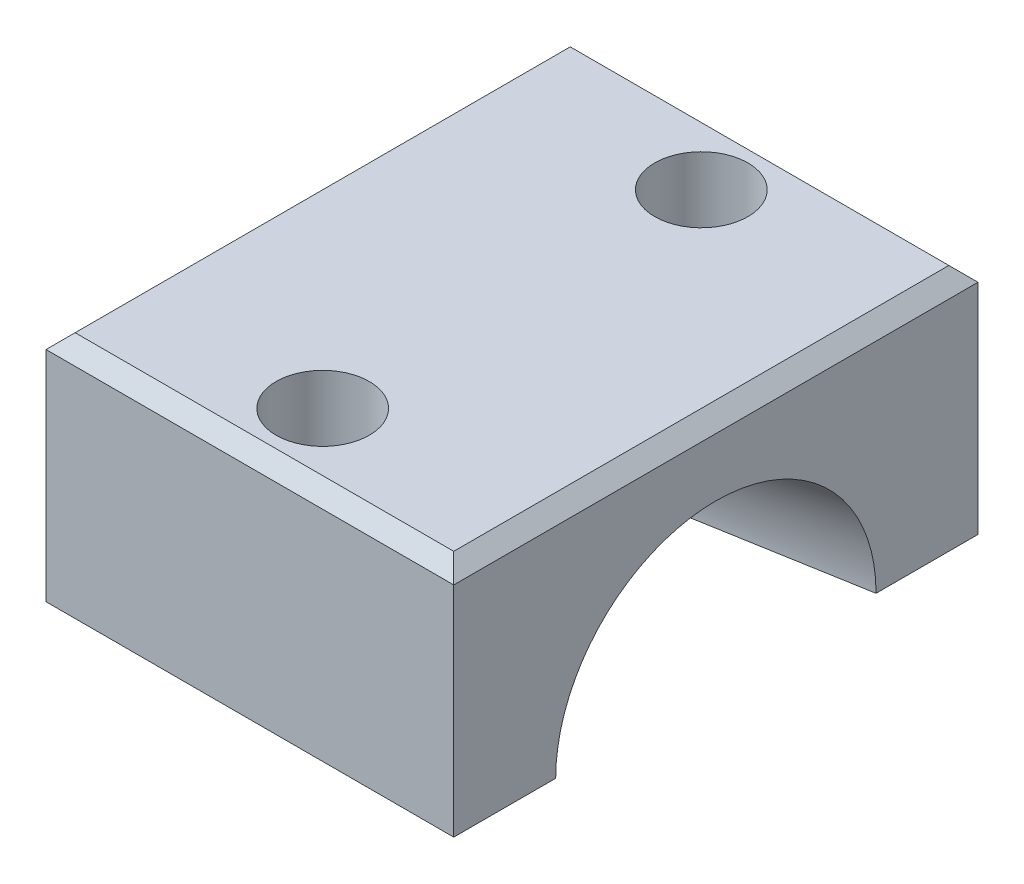
from build123d import *

# Parameters (mm, degrees)
SKETCH_1_W          = 14
SKETCH_1_H          = 18
SKETCH_1_R          = 1.6
EXTRUDE_1_DEPTH     = 4
SKETCH_2_R          = 3.5
CUT_EXTRUDE_1_DEPTH = 2.5
SKETCH_4_R          = 5.5
SKETCH_3_R          = 3.5
CHAMFER_1_SIZE      = 0.5


with BuildPart() as part:
    # 草圖1 → 填料-伸長1 (new body, symmetric)
    with BuildSketch(Plane(origin=(0, 0, 0), x_dir=(1, 0, 0), z_dir=(0, 1, 0))):
        Rectangle(SKETCH_1_W, SKETCH_1_H)
        with Locations((0, 6.5)):
            Circle(SKETCH_1_R, mode=Mode.SUBTRACT)
        with Locations((0, -6.5)):
            Circle(SKETCH_1_R, mode=Mode.SUBTRACT)
    extrude(amount=EXTRUDE_1_DEPTH, both=True)

    # 草圖2 → 除料-伸長1 (cut)
    with BuildSketch(Plane.ZY.offset(7)):
        with Locations((0, -4)):
            Circle(SKETCH_2_R)
    extrude(amount=-CUT_EXTRUDE_1_DEPTH, mode=Mode.SUBTRACT)

    # 草圖4 → 除料-疊層拉伸1 section 0
    with BuildSketch(Plane(origin=(7, 0, 0), x_dir=(0, 0, -1), z_dir=(1, 0, 0))):
        with Locations((0, -4)):
            Circle(SKETCH_4_R)
    # 草圖3 → 除料-疊層拉伸1 section 1
    with BuildSketch(Plane.ZY.offset(4.5)):
        with Locations((0, -4)):
            Circle(SKETCH_3_R)
    loft(mode=Mode.SUBTRACT)

    # 導角1
    chamfer_1_edges = [part.edges().sort_by_distance(p)[0] for p in [
        (-7, 4, 0),
        (0, 4, 9),
        (7, 4, 0),
        (0, 4, -9),
    ]]
    chamfer(chamfer_1_edges, length=CHAMFER_1_SIZE)


solid = part.part
